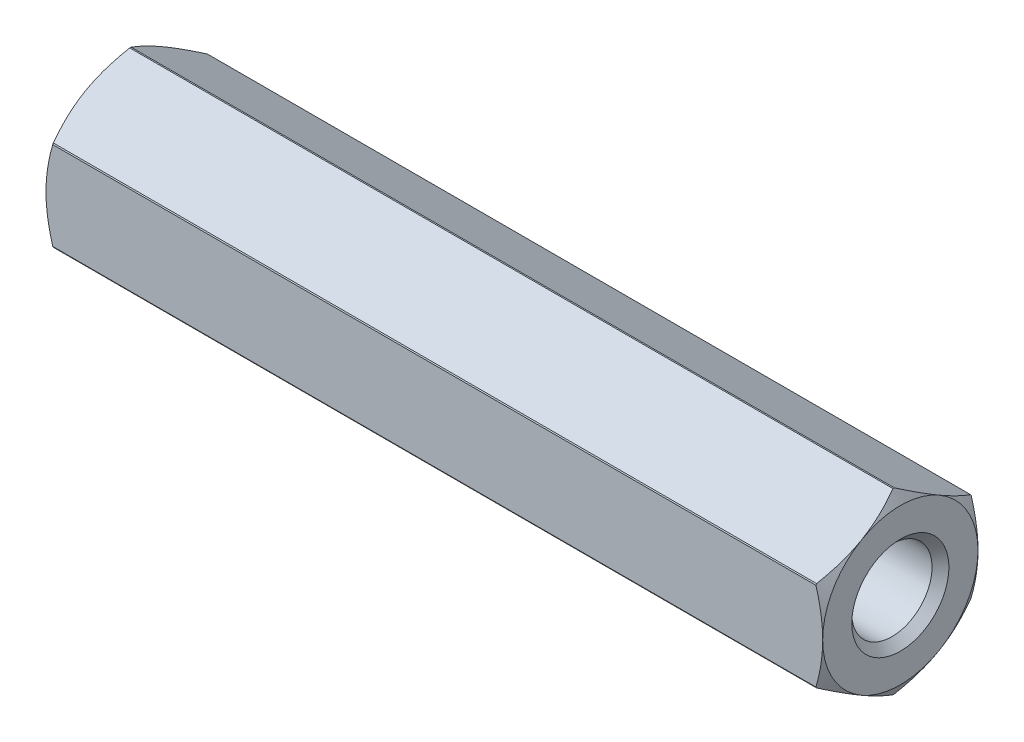
from build123d import *

# Parameters (mm, degrees)
SKETCH2_W          = 16
SKETCH2_H          = 16
CUT_EXTRUDE1_DEPTH = 40


with BuildPart() as part:
    # Sketch1 → Revolve1 (revolve)
    with BuildSketch(Plane.XY):
        Polygon((0, 0), (0, 4), (0.346410162, 4.6), (39.653589838, 4.6), (40, 4), (40, 0), align=None)
    revolve(axis=Axis((40, 0, 0), (-1, 0, 0)))

    # Sketch2 → Cut-Extrude1 (cut)
    with BuildSketch(Plane(origin=(0, 0, 0), x_dir=(0, 0, -1), z_dir=(1, 0, 0))):
        Rectangle(SKETCH2_W, SKETCH2_H)
        Polygon((-4, 2.309401077), (-4, -2.309401077), (0, -4.618802154), (4, -2.309401077), (4, 2.309401077), (0, 4.618802154), align=None, mode=Mode.SUBTRACT)
    extrude(amount=CUT_EXTRUDE1_DEPTH, mode=Mode.SUBTRACT)

    # Sketch3 → Cut-Revolve1 (revolve, cut)
    with BuildSketch(Plane.XY):
        Polygon((0, 0), (0, 2.5), (0.433, 2.067), (11.306616994, 2.067), (12.5, 0), align=None)
    revolve(axis=Axis((12.5, 0, 0), (-1, 0, 0)), mode=Mode.SUBTRACT)

    # Sketch4 → Cut-Revolve2 (revolve, cut)
    with BuildSketch(Plane.XY):
        Polygon((27.5, 0), (28.693383006, 2.067), (39.567, 2.067), (40, 2.5), (40, 0), align=None)
    revolve(axis=Axis((40, 0, 0), (-1, 0, 0)), mode=Mode.SUBTRACT)


solid = part.part
